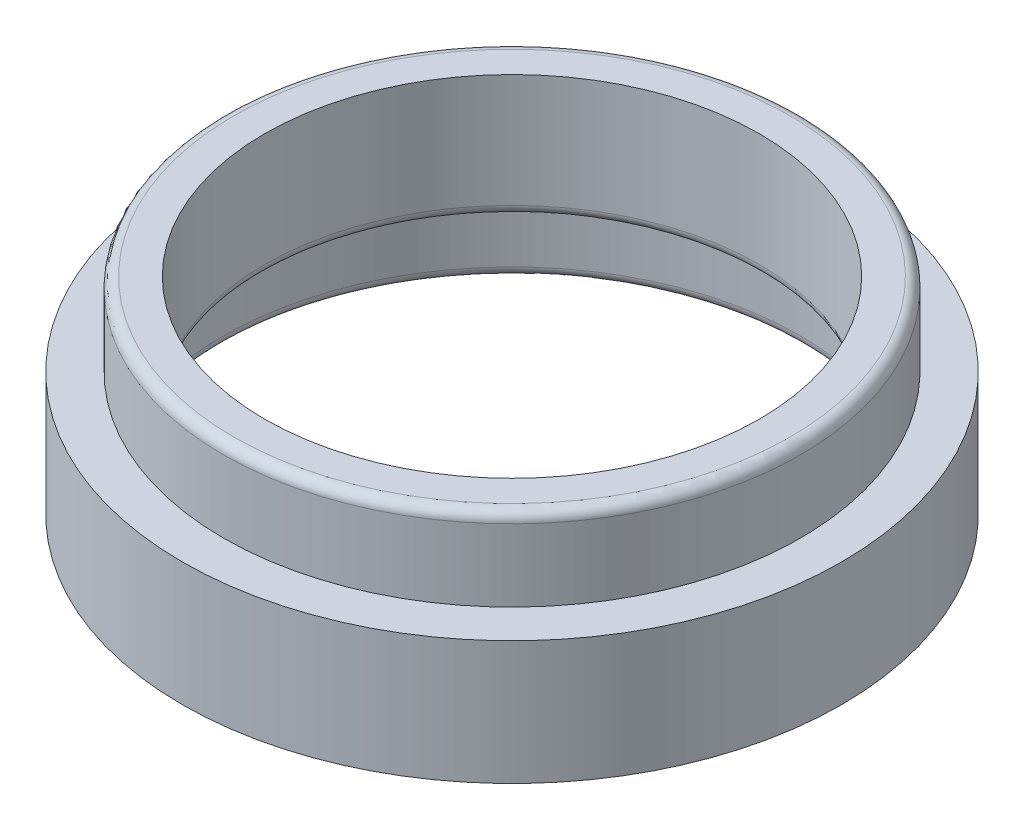
from build123d import *

# Parameters (mm, degrees)
FILLET1_R = 0.79375


with BuildPart() as part:
    # Sketch1 → Revolve1 (revolve)
    with BuildSketch(Plane(origin=(0, 0, 0), x_dir=(0, 0, -1), z_dir=(1, 0, 0))):
        Polygon((22.225, 11.1125), (22.225, 4.7625), (25.4, 4.7625), (25.4, -4.7625), (22.225, -4.7625), (22.225, 1.5875), (19.05, 1.5875), (19.05, 11.1125), align=None)
    revolve(axis=Axis((0, -32.325211936, 0), (0, 1, 0)))

    # Fillet1
    fillet1_edges = [part.edges().sort_by_distance(p)[0] for p in [
        (0, 11.1125, 22.225),
        (0, 1.5875, 19.05),
        (0, 1.5875, 22.225),
        (0, -4.7625, 22.225),
    ]]
    fillet(fillet1_edges, radius=FILLET1_R)


solid = part.part
